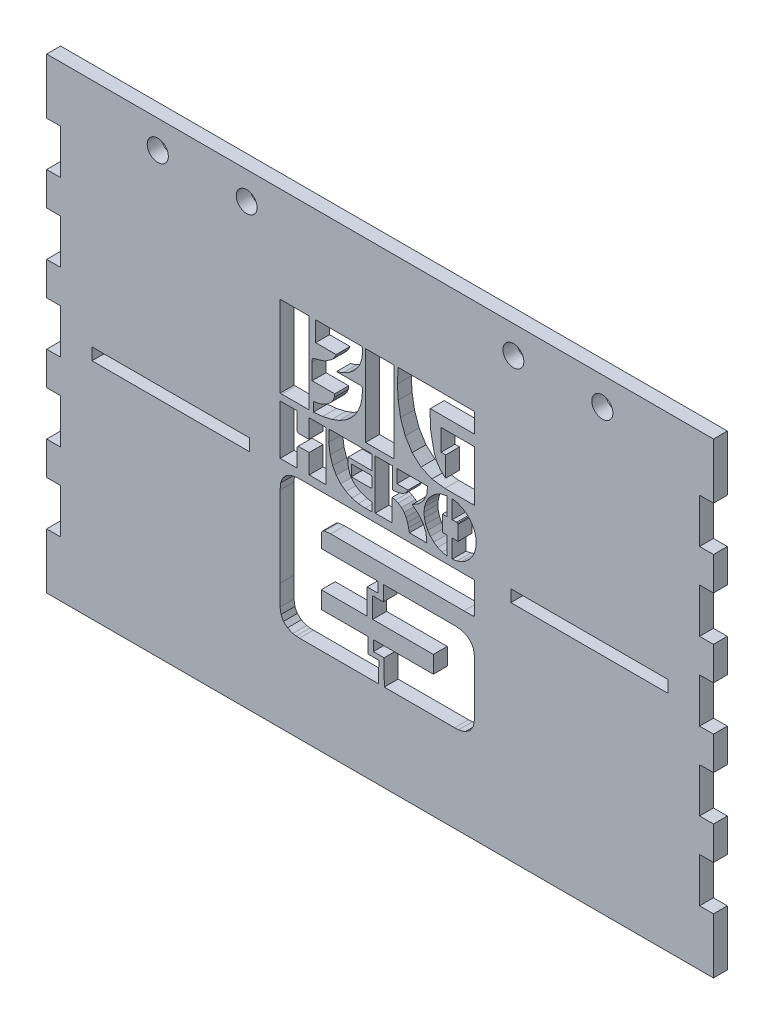
from build123d import *

# Parameters (mm, degrees)
SKETCH1_W               = 152.4
SKETCH1_H               = 106.68
SKETCH1_R               = 2.413
SKETCH1_R_2             = 2.384673294
BOSS_EXTRUDE1_DEPTH     = 3.175
SKETCH2_W               = 3.175
SKETCH2_H               = 10.16
CUT_EXTRUDE1_DEPTH      = 4.175
LPATTERN1_COUNT         = 5
LPATTERN1_PITCH         = 17.78
MIRROR1_COPY_1_SKETCH_W = 3.175
MIRROR1_COPY_1_SKETCH_H = 10.16
MIRROR1_COPY_1_DEPTH    = 4.175
MIRROR1_COPY_2_SKETCH_W = 3.175
MIRROR1_COPY_2_SKETCH_H = 10.16
MIRROR1_COPY_2_DEPTH    = 4.175
MIRROR1_COPY_3_SKETCH_W = 3.175
MIRROR1_COPY_3_SKETCH_H = 10.16
MIRROR1_COPY_3_DEPTH    = 4.175
MIRROR1_COPY_4_SKETCH_W = 3.175
MIRROR1_COPY_4_SKETCH_H = 10.16
MIRROR1_COPY_4_DEPTH    = 4.175
CUT_EXTRUDE2_REACH      = 5.175
SKETCH3_W               = 35.944165261
SKETCH3_H               = 2.7472005
SKETCH3_W_2             = 6.5062989
SKETCH3_H_2             = 18.5750073


with BuildPart() as part:
    # Sketch1 → Boss-Extrude1 (new body)
    with BuildSketch(Plane.XY):
        with Locations((-7.240186916, -0.270980049)):
            Rectangle(SKETCH1_W, SKETCH1_H)
        with Locations((-58.040186916, 46.719019951)):
            Circle(SKETCH1_R, mode=Mode.SUBTRACT)
        with Locations((-37.720186916, 46.719019951)):
            Circle(SKETCH1_R_2, mode=Mode.SUBTRACT)
        with Locations((23.239813084, 46.719019951)):
            Circle(SKETCH1_R_2, mode=Mode.SUBTRACT)
        with Locations((43.559813084, 46.719019951)):
            Circle(SKETCH1_R, mode=Mode.SUBTRACT)
    extrude(amount=BOSS_EXTRUDE1_DEPTH)

    # Sketch2 → Cut-Extrude1 (cut, through all)
    with BuildSketch(Plane.XY.offset(3.175)):
        with Locations((-81.852686916, 35.289019951)):
            Rectangle(SKETCH2_W, SKETCH2_H)
    cut_extrude1 = extrude(amount=-CUT_EXTRUDE1_DEPTH, mode=Mode.SUBTRACT)

    # LPattern1: Cut-Extrude1 ×5
    with Locations(*[(0, -i * LPATTERN1_PITCH, 0) for i in range(1, LPATTERN1_COUNT)]):
        add(cut_extrude1, mode=Mode.SUBTRACT)

    # Mirror1: Cut-Extrude1 across plane
    add(cut_extrude1.mirror(Plane.ZY.offset(7.240186916)), mode=Mode.SUBTRACT)

    # Mirror1 copy 1 sketch → Mirror1 copy 1 (cut, through all)
    with BuildSketch(Plane(origin=(-14.480373832, -17.78, 3.175), x_dir=(-1, 0, 0), z_dir=(0, 0, 1))):
        with Locations((-81.852686916, -35.289019951)):
            Rectangle(MIRROR1_COPY_1_SKETCH_W, MIRROR1_COPY_1_SKETCH_H)
    extrude(amount=-MIRROR1_COPY_1_DEPTH, mode=Mode.SUBTRACT)

    # Mirror1 copy 2 sketch → Mirror1 copy 2 (cut, through all)
    with BuildSketch(Plane(origin=(-14.480373832, -35.56, 3.175), x_dir=(-1, 0, 0), z_dir=(0, 0, 1))):
        with Locations((-81.852686916, -35.289019951)):
            Rectangle(MIRROR1_COPY_2_SKETCH_W, MIRROR1_COPY_2_SKETCH_H)
    extrude(amount=-MIRROR1_COPY_2_DEPTH, mode=Mode.SUBTRACT)

    # Mirror1 copy 3 sketch → Mirror1 copy 3 (cut, through all)
    with BuildSketch(Plane(origin=(-14.480373832, -53.34, 3.175), x_dir=(-1, 0, 0), z_dir=(0, 0, 1))):
        with Locations((-81.852686916, -35.289019951)):
            Rectangle(MIRROR1_COPY_3_SKETCH_W, MIRROR1_COPY_3_SKETCH_H)
    extrude(amount=-MIRROR1_COPY_3_DEPTH, mode=Mode.SUBTRACT)

    # Mirror1 copy 4 sketch → Mirror1 copy 4 (cut, through all)
    with BuildSketch(Plane(origin=(-14.480373832, -71.12, 3.175), x_dir=(-1, 0, 0), z_dir=(0, 0, 1))):
        with Locations((-81.852686916, -35.289019951)):
            Rectangle(MIRROR1_COPY_4_SKETCH_W, MIRROR1_COPY_4_SKETCH_H)
    extrude(amount=-MIRROR1_COPY_4_DEPTH, mode=Mode.SUBTRACT)

    # Sketch3 → Cut-Extrude2 (cut, up to next)
    with BuildSketch(Plane(origin=(0, 0.458195707, 0), x_dir=(-1, 0, 0), z_dir=(0, 0, -1)), mode=Mode.PRIVATE) as cut_extrude2_sk1:
        Polygon((22.48607026, 14.364273199), (22.48607026, 12.203203099), (20.34477406, 12.425173699), (18.23776786, 12.898832899), (16.62350896, 13.501651099), (15.20401726, 14.293635799), (13.98866536, 15.263471299), (12.98533996, 16.398813199), (12.20329936, 17.688002899), (11.65065886, 19.118695999), (11.33701966, 20.678890999), (11.26935406, 22.356814999), (11.30227246, 22.612389799), (11.39222656, 22.779953599), (11.55899026, 22.871622199), (11.82199456, 22.895853799), (16.72512166, 22.886481199), (17.18666506, 22.886481199), (15.75597196, 23.367798499), (14.49524296, 24.029481199), (13.41876556, 24.853469899), (12.54197026, 25.821590899), (11.87834446, 26.915327599), (11.44366156, 28.115934799), (11.25266626, 29.405238799), (11.31976036, 30.764380099), (21.95594686, 30.764380099), (21.95526106, 26.214668599), (17.27707636, 26.214668599), (17.64306496, 25.425312799), (18.18610426, 24.767973499), (19.93432276, 23.602684999), (21.94600276, 22.997580799), (22.41726166, 22.892767699), (22.66037776, 22.756864999), (22.75021756, 22.492717699), (22.76324776, 22.001570599), (22.76324776, 18.282248599), (17.59334446, 18.282248599), (17.66649646, 17.547985399), (17.95178926, 16.848355099), (18.42064786, 16.201645699), (19.04323996, 15.624887899), (19.79041906, 15.135569599), (20.63315296, 14.750492899), (21.54160936, 14.488288699), align=None)
    cut_extrude2_tool1 = extrude(cut_extrude2_sk1.sketch, amount=-CUT_EXTRUDE2_REACH, mode=Mode.PRIVATE) & part.part
    add(cut_extrude2_tool1.solids().sort_by_distance((-16.951181, 22.893782, 0))[0], mode=Mode.SUBTRACT)
    # Sketch3 → Cut-Extrude2 (cut, up to next)
    with BuildSketch(Plane(origin=(0, 0.458195707, 0), x_dir=(-1, 0, 0), z_dir=(0, 0, -1)), mode=Mode.PRIVATE) as cut_extrude2_sk2:
        with Locations((-40.624183475, -1.546686851)):
            Rectangle(SKETCH3_W, SKETCH3_H)
    cut_extrude2_tool2 = extrude(cut_extrude2_sk2.sketch, amount=-CUT_EXTRUDE2_REACH, mode=Mode.PRIVATE) & part.part
    add(cut_extrude2_tool2.solids().sort_by_distance((40.624183, -1.088491, 0))[0], mode=Mode.SUBTRACT)
    # Sketch3 → Cut-Extrude2 (cut, up to next)
    with BuildSketch(Plane(origin=(0, 0.458195707, 0), x_dir=(-1, 0, 0), z_dir=(0, 0, -1)), mode=Mode.PRIVATE) as cut_extrude2_sk3:
        with Locations((55.104557307, -1.546686851)):
            Rectangle(SKETCH3_W, SKETCH3_H)
    cut_extrude2_tool3 = extrude(cut_extrude2_sk3.sketch, amount=-CUT_EXTRUDE2_REACH, mode=Mode.PRIVATE) & part.part
    add(cut_extrude2_tool3.solids().sort_by_distance((-55.104557, -1.088491, 0))[0], mode=Mode.SUBTRACT)
    # Sketch3 → Cut-Extrude2 (cut, up to next)
    with BuildSketch(Plane(origin=(0, 0.458195707, 0), x_dir=(-1, 0, 0), z_dir=(0, 0, -1)), mode=Mode.PRIVATE) as cut_extrude2_sk4:
        Polygon((10.18110376, -16.237380101), (10.20407806, -22.027932401), (20.66172796, -22.027932401), (20.66172796, -25.955737601), (9.99445186, -25.955737601), (9.98953696, -29.433406541), (7.52888656, -29.433406541), (7.56237646, -34.112802821), (25.64559658, -34.106619191), (26.41577284, -34.068168671), (27.17293033, -33.941032781), (28.40698171, -33.442467611), (29.31296923, -32.636321141), (29.87665111, -31.541795771), (30.08315692, -30.178173911), (30.08377414, -25.454074901), (30.08625445, -7.012341401), (29.95850134, -5.525412701), (29.52317836, -4.399214801), (28.77222736, -3.520476401), (27.74840797, -2.920287101), (26.49453697, -2.628822101), (25.58793223, -2.583559301), (-13.65741854, -2.582302001), (-14.34138974, -2.582302001), (-14.34138974, -6.026389601), (-14.34824774, -9.478135301), (-14.32904534, -9.691304801), (-14.25715064, -9.828464801), (-14.12056214, -9.898416401), (-13.90910714, -9.913961201), (-11.95583444, -9.907217501), (18.52294636, -9.911446601), (19.87420096, -10.029289901), (20.17675306, -10.127245001), (20.41301116, -10.300866701), (20.56868776, -10.549012001), (20.62755226, -10.870195001), (20.63258146, -13.884514601), (20.13023296, -13.884514601), (7.70810896, -13.881542801), (7.72113916, -16.236694301), align=None)
    cut_extrude2_tool4 = extrude(cut_extrude2_sk4.sketch, amount=-CUT_EXTRUDE2_REACH, mode=Mode.PRIVATE) & part.part
    add(cut_extrude2_tool4.solids().sort_by_distance((-14.876889, -15.188944, 0))[0], mode=Mode.SUBTRACT)
    # Sketch3 → Cut-Extrude2 (cut, up to next)
    with BuildSketch(Plane(origin=(0, 0.458195707, 0), x_dir=(-1, 0, 0), z_dir=(0, 0, -1)), mode=Mode.PRIVATE) as cut_extrude2_sk5:
        Polygon((8.95089286, -17.348604701), (8.91797446, -22.027932401), (-4.94227214, -22.027932401), (-4.94227214, -25.955737601), (8.75921176, -25.955737601), (8.75921176, -28.322159081), (6.29856136, -28.322159081), (6.27627286, -34.112802821), (-9.83008304, -34.111568381), (-10.69213364, -34.080558791), (-12.16911824, -33.719039321), (-13.31268974, -32.931478031), (-14.05483964, -31.771241591), (-14.32710224, -30.294759911), (-14.32653074, -17.667387401), (-14.11884764, -16.354537601), (-13.53957524, -15.299777201), (-12.61694564, -14.519565401), (-11.37724784, -14.035276301), (-9.98518814, -13.883371601), (6.50452996, -13.880857001), (6.49024246, -17.348604701), align=None)
    cut_extrude2_tool5 = extrude(cut_extrude2_sk5.sketch, amount=-CUT_EXTRUDE2_REACH, mode=Mode.PRIVATE) & part.part
    add(cut_extrude2_tool5.solids().sort_by_distance((-8.626027, -19.227903, 0))[0], mode=Mode.SUBTRACT)
    # Sketch3 → Cut-Extrude2 (cut, up to next)
    with BuildSketch(Plane(origin=(0, 0.458195707, 0), x_dir=(-1, 0, 0), z_dir=(0, 0, -1)), mode=Mode.PRIVATE) as cut_extrude2_sk6:
        Polygon((3.38585446, 7.580110999), (3.39888466, 10.619347999), (-3.62839364, 10.619347999), (-3.43476944, 8.887360099), (-2.76439994, 7.381686199), (-1.64334554, 6.144617299), (-0.09983834, 5.219930299), (-1.53041714, 4.071558199), (-2.60689454, 2.725789999), (-3.26434814, 1.143420799), (-3.44037014, -0.717040301), (0.53326936, -0.717040301), (0.72620776, 0.215076199), (0.95320756, 1.131533599), (1.28056276, 1.990498099), (1.73010466, 2.759279899), (2.33097976, 3.410446999), (3.11233456, 3.914738599), (3.74795686, 4.146653299), (4.46553226, 4.358108299), (4.46553226, -0.713382701), (8.34430276, -0.713382701), (8.34430276, 10.619347999), (4.44758716, 10.619347999), (4.45181626, 7.580110999), (4.45181626, 5.851323499), (3.22286266, 5.952936199), (2.09289286, 6.293435899), (1.25084476, 6.845390599), (0.88359886, 7.580110999), align=None)
    cut_extrude2_tool6 = extrude(cut_extrude2_sk6.sketch, amount=-CUT_EXTRUDE2_REACH, mode=Mode.PRIVATE) & part.part
    add(cut_extrude2_tool6.solids().sort_by_distance((-2.813019, 5.729419, 0))[0], mode=Mode.SUBTRACT)
    # Sketch3 → Cut-Extrude2 (cut, up to next)
    with BuildSketch(Plane(origin=(0, 0.458195707, 0), x_dir=(-1, 0, 0), z_dir=(0, 0, -1)), mode=Mode.PRIVATE) as cut_extrude2_sk7:
        Polygon((-9.24520994, -1.027707701), (-9.24520994, 3.161730199), (-10.58217704, 3.161730199), (-10.56686084, 6.536437699), (-10.44524564, 6.680227099), (-10.23676244, 6.764694799), (-9.24520994, 6.777724999), (-9.24520994, 10.933672999), (-10.38318074, 10.730333299), (-11.43245474, 10.327882999), (-12.37200074, 9.745638799), (-13.18307354, 9.005774899), (-13.84475624, 8.127722299), (-14.33773214, 7.132397899), (-14.64165584, 6.040375699), (-14.73641054, 4.871429599), (-14.61365234, 3.724886299), (-14.28995474, 2.655838399), (-13.78577744, 1.684745599), (-13.12043714, 0.830810299), (-12.31370774, 0.112663399), (-11.38593464, -0.449235401), (-10.35643454, -0.835455101), align=None)
    cut_extrude2_tool7 = extrude(cut_extrude2_sk7.sketch, amount=-CUT_EXTRUDE2_REACH, mode=Mode.PRIVATE) & part.part
    add(cut_extrude2_tool7.solids().sort_by_distance((11.729555, 5.409406, 0))[0], mode=Mode.SUBTRACT)
    # Sketch3 → Cut-Extrude2 (cut, up to next)
    with BuildSketch(Plane(origin=(0, 0.458195707, 0), x_dir=(-1, 0, 0), z_dir=(0, 0, -1)), mode=Mode.PRIVATE) as cut_extrude2_sk8:
        Polygon((-8.05397534, -1.001647301), (-8.05466114, 3.161730199), (-6.99990074, 3.161730199), (-6.99990074, 6.775896199), (-7.88218244, 6.775896199), (-8.05466114, 6.775896199), (-8.05466114, 10.914470599), (-6.99921494, 10.688270899), (-6.01943534, 10.278848299), (-5.13326744, 9.705290899), (-4.36128524, 8.987829799), (-3.72246254, 8.144410099), (-3.23703044, 7.195148599), (-2.92316264, 6.158790499), (-2.80223324, 5.054309599), (-2.89035854, 3.918396199), (-3.17919464, 2.850605599), (-3.65056784, 1.870825999), (-4.28424704, 0.999402799), (-5.06080124, 0.256567099), (-5.96114234, -0.338021501), (-6.96515354, -0.764131901), align=None)
    cut_extrude2_tool8 = extrude(cut_extrude2_sk8.sketch, amount=-CUT_EXTRUDE2_REACH, mode=Mode.PRIVATE) & part.part
    add(cut_extrude2_tool8.solids().sort_by_distance((5.707671, 5.411467, 0))[0], mode=Mode.SUBTRACT)
    # Sketch3 → Cut-Extrude2 (cut, up to next)
    with BuildSketch(Plane(origin=(0, 0.458195707, 0), x_dir=(-1, 0, 0), z_dir=(0, 0, -1)), mode=Mode.PRIVATE) as cut_extrude2_sk9:
        Polygon((13.81687246, 3.740431099), (13.81687246, 6.319496299), (9.32659696, 6.306466099), (9.15354676, 6.200967199), (9.05010526, 6.018772999), (9.04941946, 4.022523499), (9.14371696, 3.851987899), (9.30247966, 3.752089699), align=None)
    cut_extrude2_tool9 = extrude(cut_extrude2_sk9.sketch, amount=-CUT_EXTRUDE2_REACH, mode=Mode.PRIVATE) & part.part
    add(cut_extrude2_tool9.solids().sort_by_distance((-11.447738, 5.487358, 0))[0], mode=Mode.SUBTRACT)
    # Sketch3 → Cut-Extrude2 (cut, up to next)
    with BuildSketch(Plane(origin=(0, 0.458195707, 0), x_dir=(-1, 0, 0), z_dir=(0, 0, -1)), mode=Mode.PRIVATE) as cut_extrude2_sk10:
        Polygon((9.06862186, 7.314134899), (14.50953046, 7.314134899), (14.58199666, 6.077065999), (14.43009196, 4.959554899), (14.05861696, 3.968459599), (13.47202936, 3.107894899), (12.67592986, 2.382889999), (11.67431896, 1.798245499), (10.47325456, 1.358533399), (9.07605136, 1.069582999), (9.07605136, -0.792706901), (10.66424986, -0.873859901), (12.20581396, -0.740014601), (13.66748236, -0.372197201), (15.01793686, 0.249823399), (16.22345896, 1.145135299), (17.25238756, 2.332712299), (18.07088986, 3.833356999), (18.64639036, 5.665243099), (18.96814486, 7.977532099), (18.92779696, 10.312909699), (18.84218626, 10.578428599), (18.57746746, 10.663353499), (9.26704666, 10.655809699), (9.06862186, 10.613175799), align=None)
    cut_extrude2_tool10 = extrude(cut_extrude2_sk10.sketch, amount=-CUT_EXTRUDE2_REACH, mode=Mode.PRIVATE) & part.part
    add(cut_extrude2_tool10.solids().sort_by_distance((-11.789076, 7.924353, 0))[0], mode=Mode.SUBTRACT)
    # Sketch3 → Cut-Extrude2 (cut, up to next)
    with BuildSketch(Plane(origin=(0, 0.458195707, 0), x_dir=(-1, 0, 0), z_dir=(0, 0, -1)), mode=Mode.PRIVATE) as cut_extrude2_sk11:
        Polygon((26.20494649, -0.173086601), (26.20494649, -0.724469801), (30.06269722, -0.724469801), (30.06269722, 10.632949699), (26.2409167, 10.632949699), (26.20618093, 10.106598199), (26.21113012, 6.790755199), (26.19501382, 6.570613399), (26.12618236, 6.419965999), (25.98665635, 6.335612599), (25.75722196, 6.314467099), (23.47202206, 6.322010899), (23.47202206, 10.628034799), (19.59016546, 10.628034799), (19.59016546, -0.710753801), (23.44664746, -0.710753801), (23.44664746, 3.731629999), (25.97983264, 3.714370699), (26.11626112, 3.569209699), (26.19501382, 3.323693299), align=None)
    cut_extrude2_tool11 = extrude(cut_extrude2_sk11.sketch, amount=-CUT_EXTRUDE2_REACH, mode=Mode.PRIVATE) & part.part
    add(cut_extrude2_tool11.solids().sort_by_distance((-24.828365, 5.421897, 0))[0], mode=Mode.SUBTRACT)
    # Sketch3 → Cut-Extrude2 (cut, up to next)
    with BuildSketch(Plane(origin=(0, 0.458195707, 0), x_dir=(-1, 0, 0), z_dir=(0, 0, -1)), mode=Mode.PRIVATE) as cut_extrude2_sk12:
        with Locations((7.29017101, 21.465789349)):
            Rectangle(SKETCH3_W_2, SKETCH3_H_2)
    cut_extrude2_tool12 = extrude(cut_extrude2_sk12.sketch, amount=-CUT_EXTRUDE2_REACH, mode=Mode.PRIVATE) & part.part
    add(cut_extrude2_tool12.solids().sort_by_distance((-7.290171, 21.923985, 0))[0], mode=Mode.SUBTRACT)
    # Sketch3 → Cut-Extrude2 (cut, up to next)
    with BuildSketch(Plane(origin=(0, 0.458195707, 0), x_dir=(-1, 0, 0), z_dir=(0, 0, -1)), mode=Mode.PRIVATE) as cut_extrude2_sk13:
        Polygon((-6.70774994, 23.779392799), (-14.31967274, 23.779392799), (-14.31967274, 12.151653799), (-13.80075074, 12.151653799), (-7.58031614, 12.155997199), (-4.61308814, 12.531815599), (-2.11700474, 13.638811099), (-0.08555084, 15.466125199), (1.48836016, 18.001184899), (2.55180736, 21.060310099), (3.09381796, 24.251337499), (3.27361186, 27.376185199), (3.12296446, 30.504004699), (3.08261656, 30.759465199), (-14.31281474, 30.759465199), (-14.31281474, 26.267360899), (-4.23772694, 26.267360899), (-4.16583224, 26.058991999), (-4.32585224, 22.029459799), (-5.10537824, 18.073765399), (-5.69516624, 16.553918299), (-6.61665284, 15.208835899), (-7.13683214, 14.745577999), (-7.75953854, 14.254430899), (-7.75953854, 18.863806999), (-6.70774994, 18.863806999), align=None)
    cut_extrude2_tool13 = extrude(cut_extrude2_sk13.sketch, amount=-CUT_EXTRUDE2_REACH, mode=Mode.PRIVATE) & part.part
    add(cut_extrude2_tool13.solids().sort_by_distance((10.513711, 23.981508, 0))[0], mode=Mode.SUBTRACT)
    # Sketch3 → Cut-Extrude2 (cut, up to next)
    with BuildSketch(Plane(origin=(0, 0.458195707, 0), x_dir=(-1, 0, 0), z_dir=(0, 0, -1)), mode=Mode.PRIVATE) as cut_extrude2_sk14:
        Polygon((30.05462764, 30.764380099), (23.49808246, 30.764380099), (23.49808246, 12.172684999), (29.69682292, 12.166512799), (30.05462764, 12.185715199), align=None)
    cut_extrude2_tool14 = extrude(cut_extrude2_sk14.sketch, amount=-CUT_EXTRUDE2_REACH, mode=Mode.PRIVATE) & part.part
    add(cut_extrude2_tool14.solids().sort_by_distance((-26.776456, 21.925363, 0))[0], mode=Mode.SUBTRACT)


solid = part.part
